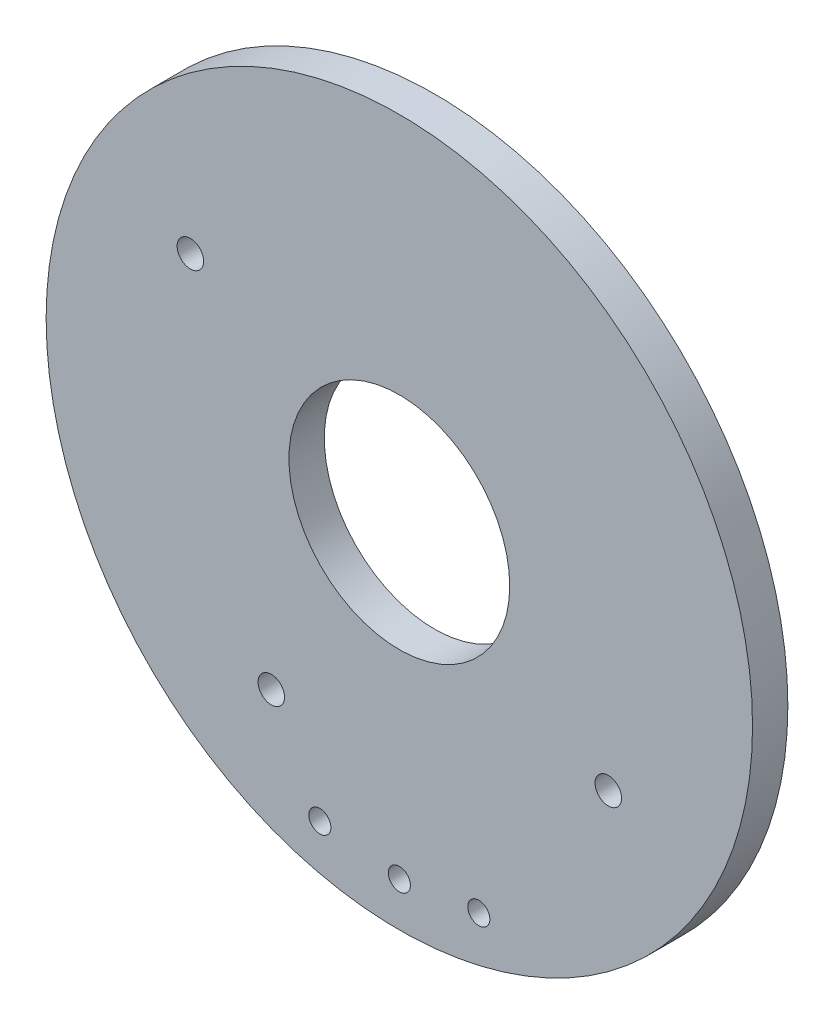
from build123d import *

# Parameters (mm, degrees)
CROQUIS1_R              = 8
CROQUIS1_R_2            = 2.5
SALIENTE_EXTRUIR1_DEPTH = 0.8
CROQUIS2_R              = 0.25
CROQUIS2_R_2            = 0.3
CORTAR_EXTRUIR1_DEPTH   = 1.6


with BuildPart() as part:
    # Croquis1 → Saliente-Extruir1 (new body)
    with BuildSketch(Plane.XY):
        Circle(CROQUIS1_R)
        Circle(CROQUIS1_R_2, mode=Mode.SUBTRACT)
    extrude(amount=SALIENTE_EXTRUIR1_DEPTH)

    # Croquis2 → Cortar-Extruir1 (cut)
    with BuildSketch(Plane.XY.offset(0.8)):
        with Locations((0, -7)):
            Circle(CROQUIS2_R)
        with Locations((-1.8, -6.76461381)):
            Circle(CROQUIS2_R)
        with Locations((1.8, -6.76461381)):
            Circle(CROQUIS2_R)
        with Locations((4.73299588, -2.9)):
            Circle(CROQUIS2_R_2)
        with Locations((-2.9, -4.73299588)):
            Circle(CROQUIS2_R_2)
        with Locations((-4.73299588, 2.9)):
            Circle(CROQUIS2_R_2)
    extrude(amount=-CORTAR_EXTRUIR1_DEPTH, mode=Mode.SUBTRACT)


solid = part.part
